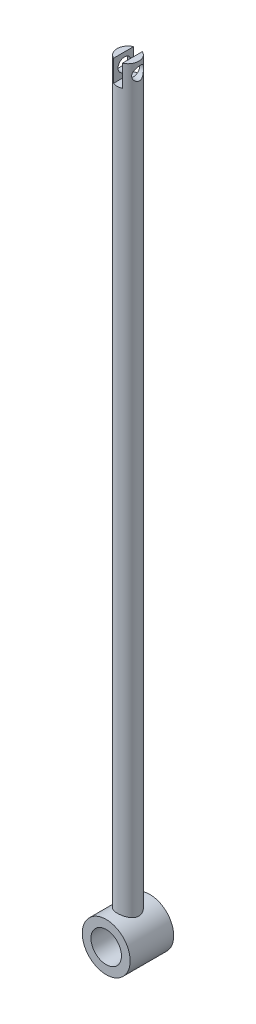
from build123d import *

# Parameters (mm, degrees)
SKETCH1_R               = 5.5
SKETCH1_R_2             = 3.5
BOSS_EXTRUDE1_DEPTH     = 10
SKETCH2_R               = 2.5
BOSS_EXTRUDE2_DEPTH     = 170
SKETCH3_R               = 3.5
CUT_EXTRUDE1_DEPTH      = 11
BOSS_EXTRUDE3_DEPTH     = 5
SKETCH5_R               = 1.5
CUT_EXTRUDE2_DEPTH      = 7.5
CUT_EXTRUDE2_DEPTH_BACK = 5


with BuildPart() as part:
    # Sketch1 → Boss-Extrude1 (new body)
    with BuildSketch(Plane.XY):
        Circle(SKETCH1_R)
        Circle(SKETCH1_R_2, mode=Mode.SUBTRACT)
    extrude(amount=BOSS_EXTRUDE1_DEPTH)

    # Sketch2 → Boss-Extrude2 (add)
    with BuildSketch(Plane(origin=(0, 0, 0), x_dir=(1, 0, 0), z_dir=(0, 1, 0))):
        with Locations((0, -5)):
            Circle(SKETCH2_R)
    extrude(amount=BOSS_EXTRUDE2_DEPTH)

    # Sketch3 → Cut-Extrude1 (cut, through all)
    with BuildSketch(Plane.XY.offset(10)):
        Circle(SKETCH3_R)
    extrude(amount=-CUT_EXTRUDE1_DEPTH, mode=Mode.SUBTRACT)

    # Sketch4 → Boss-Extrude3 (add)
    with BuildSketch(Plane(origin=(0, 170, 0), x_dir=(1, 0, 0), z_dir=(0, 1, 0))):
        with BuildLine():
            Line((1, -7.291288), (1, -2.708712))
            ThreePointArc((1, -2.708712), (2.5, -5), (1, -7.291288))
        make_face()
        with BuildLine():
            Line((-1, -7.291288), (-1, -2.708712))
            ThreePointArc((-1, -2.708712), (-2.5, -5), (-1, -7.291288))
        make_face()
    extrude(amount=BOSS_EXTRUDE3_DEPTH)

    # Sketch5 → Cut-Extrude2 (cut, two sides)
    with BuildSketch(Plane(origin=(-1, 0, 0), x_dir=(0, 0, -1), z_dir=(1, 0, 0))) as cut_extrude2_sk:
        with Locations((-4.791288, 172.5)):
            Circle(SKETCH5_R)
    extrude(amount=CUT_EXTRUDE2_DEPTH, mode=Mode.SUBTRACT)
    extrude(cut_extrude2_sk.sketch, amount=-CUT_EXTRUDE2_DEPTH_BACK, mode=Mode.SUBTRACT)


solid = part.part
